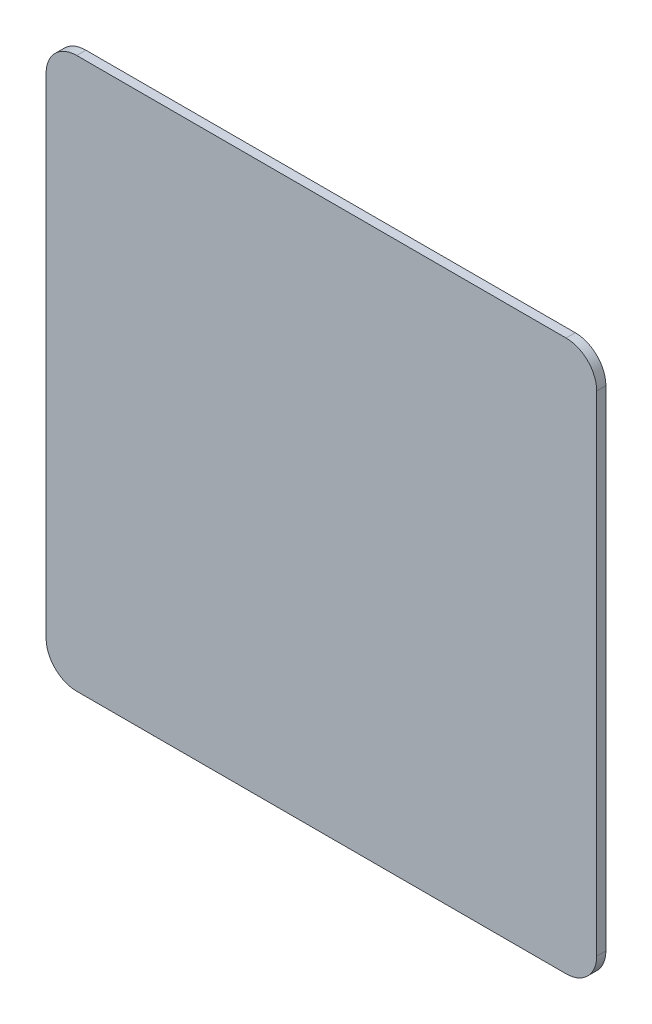
from build123d import *

# Parameters (mm, degrees)
BOSS_EXTRUDE1_DEPTH = 3


with BuildPart() as part:
    # Sketch1 → Boss-Extrude1 (new body)
    with BuildSketch(Plane.XY):
        with BuildLine():
            Line((-90, 80), (-90, -80))
            ThreePointArc((-90, -80), (-87.071067812, -87.071067812), (-80, -90))
            Line((-80, -90), (80, -90))
            ThreePointArc((80, -90), (87.071067812, -87.071067812), (90, -80))
            Line((90, -80), (90, 80))
            ThreePointArc((90, 80), (87.071067812, 87.071067812), (80, 90))
            Line((80, 90), (-80, 90))
            ThreePointArc((-80, 90), (-87.071067812, 87.071067812), (-90, 80))
        make_face()
    extrude(amount=BOSS_EXTRUDE1_DEPTH)


solid = part.part
